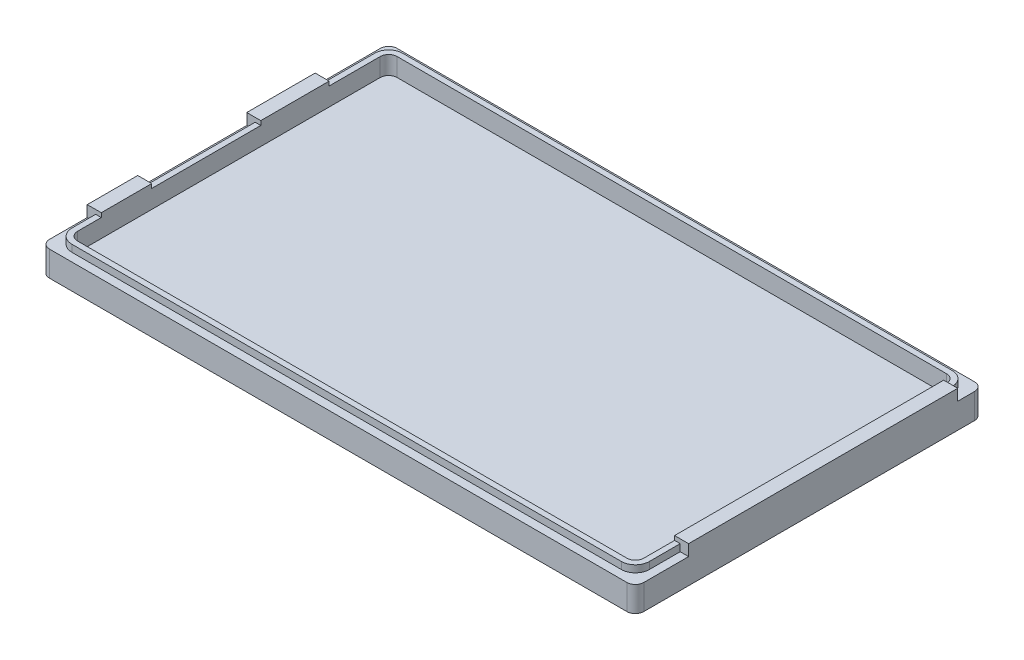
from build123d import *

# Parameters (mm, degrees)
SKETCH1_W           = 106
SKETCH1_H           = 62
BOSS_EXTRUDE1_DEPTH = 2.5
FILLET1_R           = 1.5
BOSS_EXTRUDE2_DEPTH = 2
BOSS_EXTRUDE3_DEPTH = 1.25
SKETCH4_W           = 2.5
SKETCH4_H           = 9
SKETCH4_H_2         = 12.2
SKETCH4_H_3         = 48
BOSS_EXTRUDE4_DEPTH = 2


with BuildPart() as part:
    # Sketch1 → Boss-Extrude1 (new body)
    with BuildSketch(Plane(origin=(0, 0, 0), x_dir=(1, 0, 0), z_dir=(0, 1, 0))):
        with Locations((53, 31)):
            Rectangle(SKETCH1_W, SKETCH1_H)
    extrude(amount=BOSS_EXTRUDE1_DEPTH)

    # Fillet1
    fillet1_edges = [part.edges().sort_by_distance(p)[0] for p in [
        (0, 1.25, 0),
        (0, 1.25, -62),
        (106, 1.25, -62),
        (106, 1.25, 0),
    ]]
    fillet(fillet1_edges, radius=FILLET1_R)

    # Sketch2 → Boss-Extrude2 (add)
    with BuildSketch(Plane(origin=(0, 2.5, 0), x_dir=(1, 0, 0), z_dir=(0, 1, 0))):
        with BuildLine():
            Line((104.5, 62), (1.5, 62))
            ThreePointArc((1.5, 62), (0.439339828, 61.560660172), (0, 60.5))
            Line((0, 60.5), (0, 1.5))
            ThreePointArc((0, 1.5), (0.439339828, 0.439339828), (1.5, 0))
            Line((1.5, 0), (104.5, 0))
            ThreePointArc((104.5, 0), (105.560660172, 0.439339828), (106, 1.5))
            Line((106, 1.5), (106, 60.5))
            ThreePointArc((106, 60.5), (105.560660172, 61.560660172), (104.5, 62))
        make_face()
        with BuildLine():
            Line((102, 59.5), (4, 59.5))
            ThreePointArc((4, 59.5), (2.939339828, 59.060660172), (2.5, 58))
            Line((2.5, 58), (2.5, 4))
            ThreePointArc((2.5, 4), (2.939339828, 2.939339828), (4, 2.5))
            Line((4, 2.5), (102, 2.5))
            ThreePointArc((102, 2.5), (103.060660172, 2.939339828), (103.5, 4))
            Line((103.5, 4), (103.5, 58))
            ThreePointArc((103.5, 58), (103.060660172, 59.060660172), (102, 59.5))
        make_face(mode=Mode.SUBTRACT)
    extrude(amount=BOSS_EXTRUDE2_DEPTH)

    # Sketch3 → Boss-Extrude3 (add)
    with BuildSketch(Plane(origin=(0, 4.5, 0), x_dir=(1, 0, 0), z_dir=(0, 1, 0))):
        with BuildLine():
            Line((4, 1.5), (102, 1.5))
            ThreePointArc((102, 1.5), (103.767766953, 2.232233047), (104.5, 4))
            Line((104.5, 4), (104.5, 58))
            ThreePointArc((104.5, 58), (103.767766953, 59.767766953), (102, 60.5))
            Line((102, 60.5), (4, 60.5))
            ThreePointArc((4, 60.5), (2.232233047, 59.767766953), (1.5, 58))
            Line((1.5, 58), (1.5, 4))
            ThreePointArc((1.5, 4), (2.232233047, 2.232233047), (4, 1.5))
        make_face()
        with BuildLine():
            Line((4, 2.5), (102, 2.5))
            ThreePointArc((102, 2.5), (103.060660172, 2.939339828), (103.5, 4))
            Line((103.5, 4), (103.5, 58))
            ThreePointArc((103.5, 58), (103.060660172, 59.060660172), (102, 59.5))
            Line((102, 59.5), (4, 59.5))
            ThreePointArc((4, 59.5), (2.939339828, 59.060660172), (2.5, 58))
            Line((2.5, 58), (2.5, 4))
            ThreePointArc((2.5, 4), (2.939339828, 2.939339828), (4, 2.5))
        make_face(mode=Mode.SUBTRACT)
    extrude(amount=BOSS_EXTRUDE3_DEPTH)

    # Sketch4 → Boss-Extrude4 (add)
    with BuildSketch(Plane(origin=(0, 4.5, 0), x_dir=(1, 0, 0), z_dir=(0, 1, 0))):
        with Locations((1.25, 12.74)):
            Rectangle(SKETCH4_W, SKETCH4_H)
        with Locations((1.25, 42.79)):
            Rectangle(SKETCH4_W, SKETCH4_H_2)
        with Locations((104.75, 33.5)):
            Rectangle(SKETCH4_W, SKETCH4_H_3)
    extrude(amount=BOSS_EXTRUDE4_DEPTH)


solid = part.part
